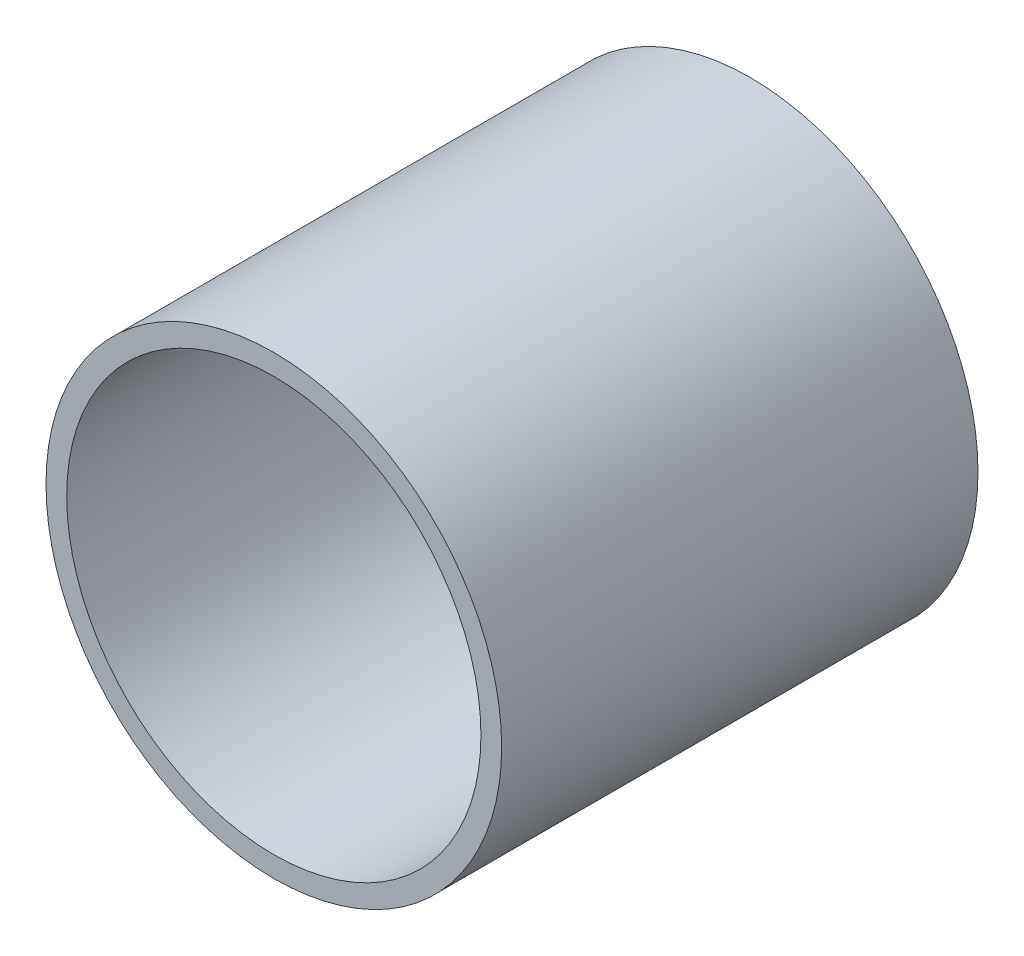
from build123d import *

# Parameters (mm, degrees)
CROQUIS1_R              = 11
CROQUIS1_R_2            = 10
SALIENTE_EXTRUIR1_DEPTH = 23


with BuildPart() as part:
    # Croquis1 → Saliente-Extruir1 (new body)
    with BuildSketch(Plane.XY):
        Circle(CROQUIS1_R)
        Circle(CROQUIS1_R_2, mode=Mode.SUBTRACT)
    extrude(amount=SALIENTE_EXTRUIR1_DEPTH)


solid = part.part
